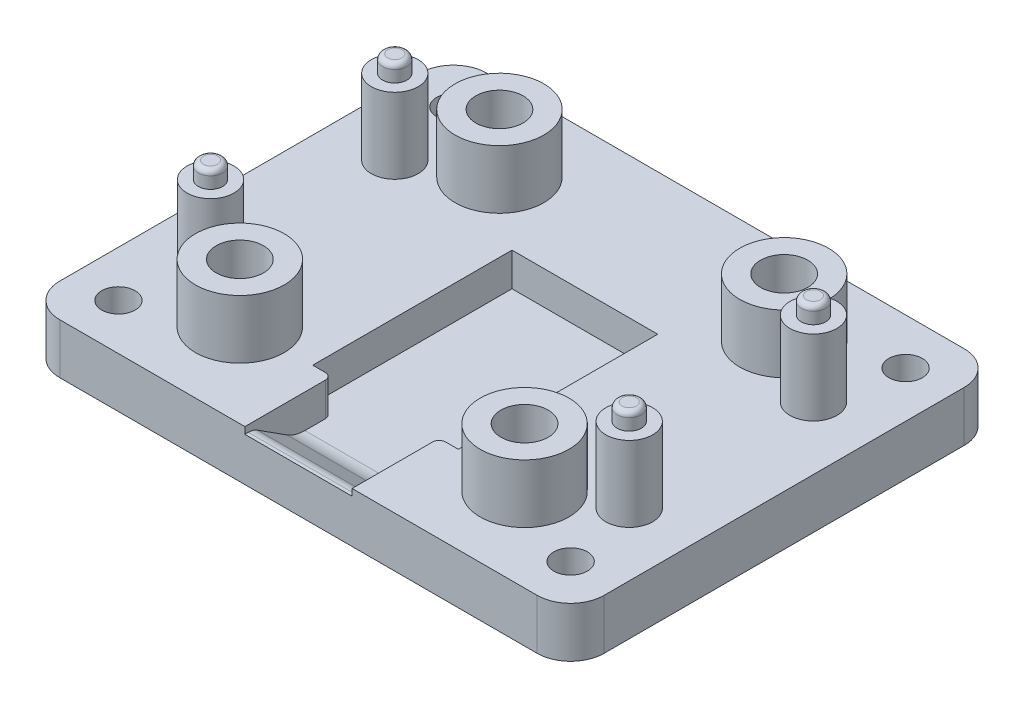
from build123d import *

# Parameters (mm, degrees)
SKETCH_1_W          = 32.5
SKETCH_1_H          = 25.5
EXTRUDE_1_DEPTH     = 3
EXTRUDE_2_DEPTH     = 1.5
SKETCH_5_R          = 1.4
EXTRUDE_3_DEPTH     = 4.5
SKETCH_6_R          = 0.725
EXTRUDE_4_DEPTH     = 1
SKETCH_7_R          = 1
CUT_EXTRUDE_1_DEPTH = 10
SKETCH_8_R          = 2
CUT_EXTRUDE_2_DEPTH = 1
FILLET_1_R          = 2
SKETCH_9_R          = 2.65
EXTRUDE_5_DEPTH     = 3.5
SKETCH_11_R         = 1.05
CUT_EXTRUDE_4_DEPTH = 100
SKETCH_12_R         = 1.41
CUT_EXTRUDE_5_DEPTH = 5.5
FILLET_2_R          = 0.3
CUT_EXTRUDE_8_DEPTH = 2
CUT_EXTRUDE_9_DEPTH = 1.5
EXTRUDE_6_DEPTH     = 6.4
FILLET_3_R          = 2
FILLET_5_R          = 1
FILLET_6_R          = 0.4


with BuildPart() as part:
    # 草图1 → 凸台-拉伸1 (new body)
    with BuildSketch(Plane(origin=(0, 0, 0), x_dir=(1, 0, 0), z_dir=(0, 1, 0))):
        Rectangle(SKETCH_1_W, SKETCH_1_H)
    extrude(amount=EXTRUDE_1_DEPTH)

    # 草图2 → 凸台-拉伸2 (add)
    with BuildSketch(Plane(origin=(0, 3, 0), x_dir=(1, 0, 0), z_dir=(0, 1, 0))):
        Polygon((-5.35, 5.35), (5.35, 5.35), (5.35, -7.55), (4.35, -7.55), (4.35, 4.35), (-4.35, 4.35), (-4.35, -7.55), (-5.35, -7.55), align=None)
    extrude(amount=EXTRUDE_2_DEPTH)

    # 草图5 → 凸台-拉伸3 (add)
    with BuildSketch(Plane(origin=(0, 3, 0), x_dir=(1, 0, 0), z_dir=(0, 1, 0))):
        with Locations((12.5, 5.5)):
            Circle(SKETCH_5_R)
        with Locations((12.5, -5.5)):
            Circle(SKETCH_5_R)
        with Locations((-12.5, -5.5)):
            Circle(SKETCH_5_R)
        with Locations((-12.5, 5.5)):
            Circle(SKETCH_5_R)
    extrude(amount=EXTRUDE_3_DEPTH)

    # 草图6 → 凸台-拉伸4 (add)
    with BuildSketch(Plane(origin=(0, 7.5, 0), x_dir=(1, 0, 0), z_dir=(0, 1, 0))):
        with Locations((-12.5, -5.5)):
            Circle(SKETCH_6_R)
        with Locations((-12.5, 5.5)):
            Circle(SKETCH_6_R)
        with Locations((12.5, 5.5)):
            Circle(SKETCH_6_R)
        with Locations((12.5, -5.5)):
            Circle(SKETCH_6_R)
    extrude(amount=EXTRUDE_4_DEPTH)

    # 草图7 → 切除-拉伸1 (cut)
    with BuildSketch(Plane(origin=(0, 3, 0), x_dir=(1, 0, 0), z_dir=(0, 1, 0))):
        with Locations((13.5, 10)):
            Circle(SKETCH_7_R)
        with Locations((-13.5, 10)):
            Circle(SKETCH_7_R)
        with Locations((-13.5, -10)):
            Circle(SKETCH_7_R)
        with Locations((13.5, -10)):
            Circle(SKETCH_7_R)
    extrude(amount=-CUT_EXTRUDE_1_DEPTH, mode=Mode.SUBTRACT)

    # 草图8 → 切除-拉伸2 (cut)
    with BuildSketch(Plane.XZ):
        with Locations((-13.5, 10)):
            Circle(SKETCH_8_R)
        with Locations((13.5, 10)):
            Circle(SKETCH_8_R)
        with Locations((13.5, -10)):
            Circle(SKETCH_8_R)
        with Locations((-13.5, -10)):
            Circle(SKETCH_8_R)
    extrude(amount=-CUT_EXTRUDE_2_DEPTH, mode=Mode.SUBTRACT)

    # 圆角1
    fillet_1_edges = [part.edges().sort_by_distance(p)[0] for p in [
        (16.25, 1.5, 12.75),
        (-16.25, 1.5, 12.75),
        (-16.25, 1.5, -12.75),
        (16.25, 1.5, -12.75),
    ]]
    fillet(fillet_1_edges, radius=FILLET_1_R)

    # 草图9 → 凸台-拉伸5 (add)
    with BuildSketch(Plane(origin=(0, 3, 0), x_dir=(1, 0, 0), z_dir=(0, 1, 0))):
        with Locations((8.5, 7.75)):
            Circle(SKETCH_9_R)
        with Locations((-8.5, 7.75)):
            Circle(SKETCH_9_R)
        with Locations((-8.5, -7.75)):
            Circle(SKETCH_9_R)
        with Locations((8.5, -7.75)):
            Circle(SKETCH_9_R)
    extrude(amount=EXTRUDE_5_DEPTH)

    # 草图11 → 切除-拉伸4 (cut)
    with BuildSketch(Plane(origin=(0, 6.5, 0), x_dir=(1, 0, 0), z_dir=(0, 1, 0))):
        with Locations((-8.5, 7.75)):
            Circle(SKETCH_11_R)
        with Locations((-8.5, -7.75)):
            Circle(SKETCH_11_R)
        with Locations((8.5, -7.75)):
            Circle(SKETCH_11_R)
        with Locations((8.5, 7.75)):
            Circle(SKETCH_11_R)
    extrude(amount=-CUT_EXTRUDE_4_DEPTH, mode=Mode.SUBTRACT)

    # 草图12 → 切除-拉伸5 (cut)
    with BuildSketch(Plane(origin=(0, 6.5, 0), x_dir=(1, 0, 0), z_dir=(0, 1, 0))):
        with Locations((-8.5, 7.75)):
            Circle(SKETCH_12_R)
        with Locations((8.5, 7.75)):
            Circle(SKETCH_12_R)
        with Locations((-8.5, -7.75)):
            Circle(SKETCH_12_R)
        with Locations((8.5, -7.75)):
            Circle(SKETCH_12_R)
    extrude(amount=-CUT_EXTRUDE_5_DEPTH, mode=Mode.SUBTRACT)

    # 圆角2
    fillet_2_edges = [part.edges().sort_by_distance(p)[0] for p in [
        (-13.225, 8.5, 5.5),
        (-13.225, 8.5, -5.5),
        (11.775, 8.5, -5.5),
        (11.775, 8.5, 5.5),
    ]]
    fillet(fillet_2_edges, radius=FILLET_2_R)

    # 草图15 → 切除-拉伸8 (cut)
    with BuildSketch(Plane(origin=(0, 3, 0), x_dir=(1, 0, 0), z_dir=(0, 1, 0))):
        Polygon((-4.35, 4.35), (4.35, 4.35), (4.35, -7.55), (3.2, -7.55), (3.2, -12.75), (-3.2, -12.75), (-3.2, -7.55), (-4.35, -7.55), align=None)
    extrude(amount=-CUT_EXTRUDE_8_DEPTH, mode=Mode.SUBTRACT)

    # 草图17 → 切除-拉伸9 (cut)
    with BuildSketch(Plane(origin=(0, 4.5, 0), x_dir=(1, 0, 0), z_dir=(0, 1, 0))):
        Polygon((-4.35, -7.55), (-4.35, 4.35), (4.35, 4.35), (4.35, -7.55), (5.35, -7.55), (5.35, 5.35), (-5.35, 5.35), (-5.35, -7.55), align=None)
    extrude(amount=-CUT_EXTRUDE_9_DEPTH, mode=Mode.SUBTRACT)

    # 草图18 → 凸台-拉伸6 (add)
    with BuildSketch(Plane.ZY.offset(-3.2)):
        Polygon((12.75, 1), (9.75, 1), (12.25, 2.6), (12.75, 2.6), align=None)
    extrude(amount=EXTRUDE_6_DEPTH)

    # 圆角3
    fillet_3_edges = [part.edges().sort_by_distance(p)[0] for p in [
        (0, 1, 9.75),
    ]]
    fillet(fillet_3_edges, radius=FILLET_3_R)

    # 圆角5
    fillet_5_edges = [part.edges().sort_by_distance(p)[0] for p in [
        (0, 2.6, 12.25),
    ]]
    fillet(fillet_5_edges, radius=FILLET_5_R)

    # 圆角6
    fillet_6_edges = [part.edges().sort_by_distance(p)[0] for p in [
        (3.2, 2, 7.55),
        (-3.2, 2, 7.55),
    ]]
    fillet(fillet_6_edges, radius=FILLET_6_R)


solid = part.part
